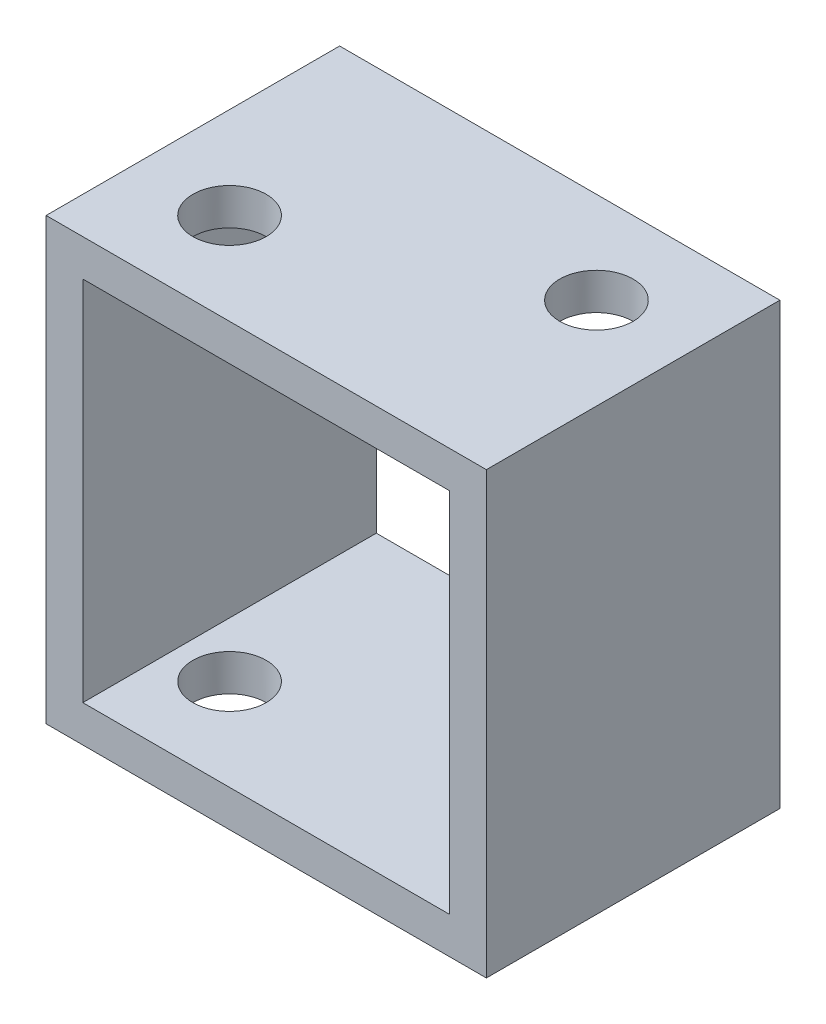
from build123d import *

# Parameters (mm, degrees)
SKETCH1_W           = 38.1
SKETCH1_H           = 38.1
SKETCH1_W_2         = 31.75
SKETCH1_H_2         = 31.75
BOSS_EXTRUDE1_DEPTH = 25.4
SKETCH2_R           = 3.175
CUT_EXTRUDE1_DEPTH  = 39.1


with BuildPart() as part:
    # Sketch1 → Boss-Extrude1 (new body)
    with BuildSketch(Plane.XY):
        with Locations((19.05, 19.05)):
            Rectangle(SKETCH1_W, SKETCH1_H)
        with Locations((19.05, 19.05)):
            Rectangle(SKETCH1_W_2, SKETCH1_H_2, mode=Mode.SUBTRACT)
    extrude(amount=BOSS_EXTRUDE1_DEPTH)

    # Sketch2 → Cut-Extrude1 (cut, through all)
    with BuildSketch(Plane.XZ):
        with Locations((7.9375, 17.4625)):
            Circle(SKETCH2_R)
        with Locations((30.1625, 7.9375)):
            Circle(SKETCH2_R)
    extrude(amount=-CUT_EXTRUDE1_DEPTH, mode=Mode.SUBTRACT)


solid = part.part
